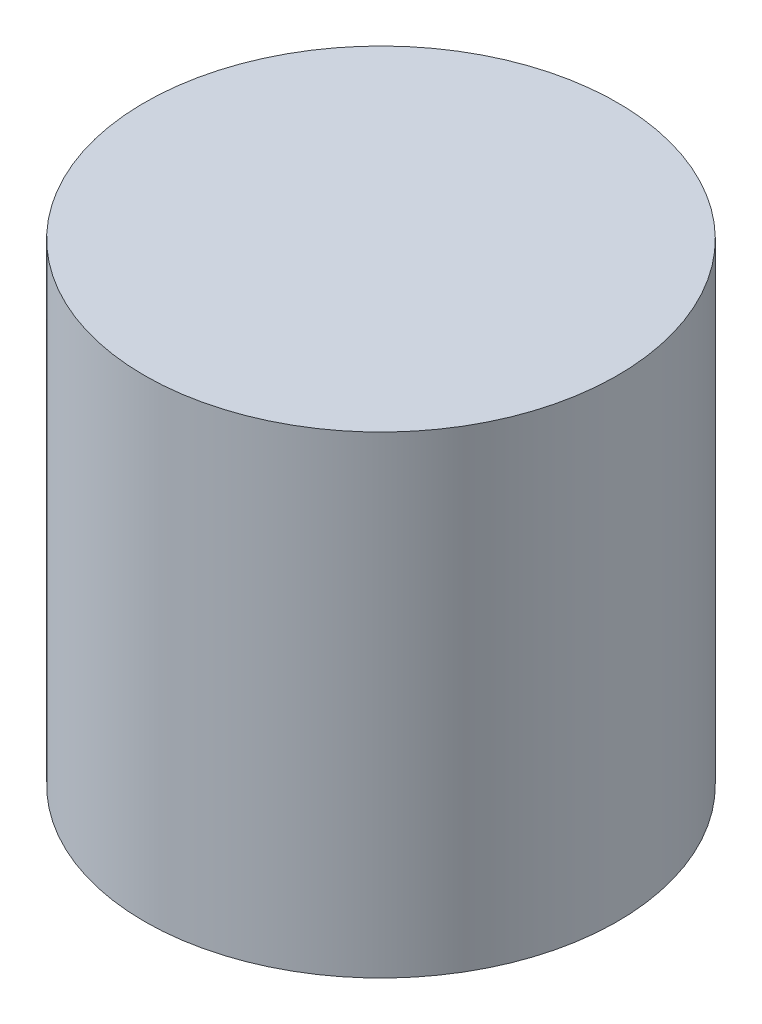
from build123d import *

# Parameters (mm, degrees)
SKETCH1_R           = 12.7
BOSS_EXTRUDE1_DEPTH = 12.7


with BuildPart() as part:
    # Sketch1 → Boss-Extrude1 (new body, symmetric)
    with BuildSketch(Plane(origin=(0, 0, 0), x_dir=(1, 0, 0), z_dir=(0, 1, 0))):
        Circle(SKETCH1_R)
    extrude(amount=BOSS_EXTRUDE1_DEPTH, both=True)


solid = part.part
